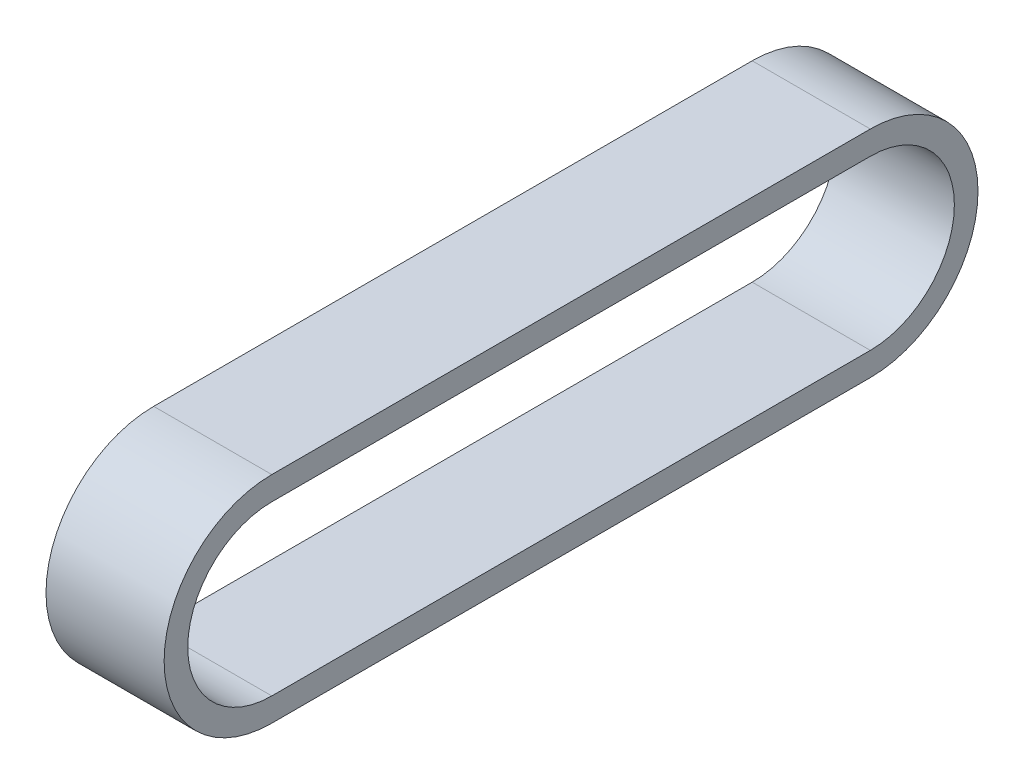
from build123d import *

# Parameters (mm, degrees)
EXTRUDE_1_DEPTH      = 15
EXTRUDE_1_DEPTH_BACK = 15
CUT_EXTRUDE_1_DEPTH  = 30


with BuildPart() as part:
    # 스케치2 → 보스-돌출1 (new, two sides: drawn at the far end of the back side and taken through both)
    with BuildSketch(Plane(origin=(0, 0, 0), x_dir=(0, 0, -1), z_dir=(1, 0, 0)).offset(-EXTRUDE_1_DEPTH_BACK)):
        with BuildLine():
            Line((-76, 27.345), (76, 27.345))
            ThreePointArc((76, 27.345), (103.345, 0), (76, -27.345))
            Line((76, -27.345), (-76, -27.345))
            ThreePointArc((-76, -27.345), (-103.345, 0), (-76, 27.345))
        make_face()
    extrude(amount=EXTRUDE_1_DEPTH + EXTRUDE_1_DEPTH_BACK)

    # 스케치3 → 컷-돌출1 (cut)
    with BuildSketch(Plane(origin=(15, 0, 0), x_dir=(0, 0, -1), z_dir=(1, 0, 0))):
        with BuildLine():
            Line((-76, 21.345), (76, 21.345))
            ThreePointArc((76, 21.345), (97.345, 0), (76, -21.345))
            Line((76, -21.345), (-76, -21.345))
            ThreePointArc((-76, -21.345), (-97.345, 0), (-76, 21.345))
        make_face()
    extrude(amount=-CUT_EXTRUDE_1_DEPTH, mode=Mode.SUBTRACT)


solid = part.part
